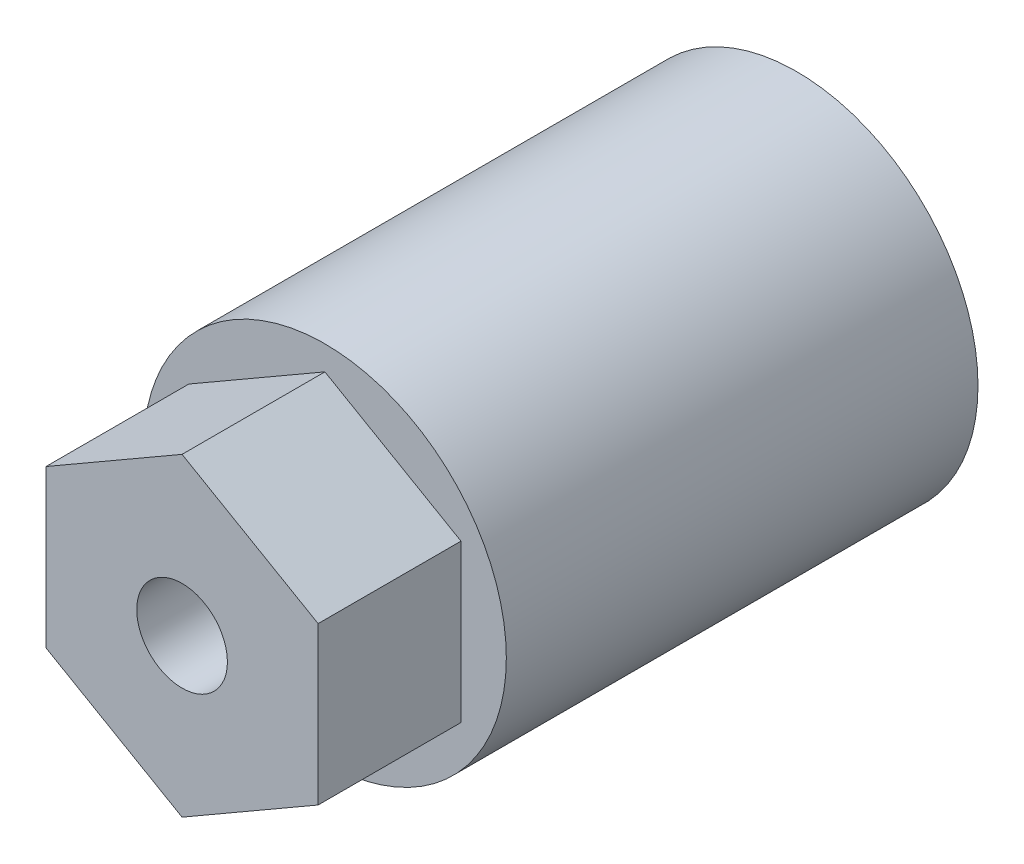
from build123d import *

# Parameters (mm, degrees)
CROQUIS1_R              = 8
CROQUIS1_R_2            = 3.1
SALIENTE_EXTRUIR1_DEPTH = 20.8
CROQUIS2_R              = 3.1
CROQUIS2_R_2            = 2
SALIENTE_EXTRUIR2_DEPTH = 2.2
CROQUIS3_R              = 2
SALIENTE_EXTRUIR3_DEPTH = 6.3
CORTAR_EXTRUIR1_REACH   = 10
CROQUIS4_R              = 2.5


with BuildPart() as part:
    # Croquis1 → Saliente-Extruir1 (new body)
    with BuildSketch(Plane.XY):
        Circle(CROQUIS1_R)
        Circle(CROQUIS1_R_2, mode=Mode.SUBTRACT)
    extrude(amount=SALIENTE_EXTRUIR1_DEPTH)

    # Croquis2 → Saliente-Extruir2 (add)
    with BuildSketch(Plane.XY.offset(20.8)):
        Circle(CROQUIS2_R)
        Circle(CROQUIS2_R_2, mode=Mode.SUBTRACT)
    extrude(amount=-SALIENTE_EXTRUIR2_DEPTH)

    # Croquis3 → Saliente-Extruir3 (add)
    with BuildSketch(Plane.XY.offset(20.8)):
        Polygon((0, 6.92820323), (-6, 3.464101615), (-6, -3.464101615), (0, -6.92820323), (6, -3.464101615), (6, 3.464101615), align=None)
        Circle(CROQUIS3_R, mode=Mode.SUBTRACT)
    extrude(amount=SALIENTE_EXTRUIR3_DEPTH)

    # Croquis4 → Cortar-Extruir1 (cut, up to next)
    with BuildSketch(Plane(origin=(0, 0, 0), x_dir=(0, 0, -1), z_dir=(1, 0, 0)), mode=Mode.PRIVATE) as cortar_extruir1_sk1:
        with Locations((-6, 0)):
            Circle(CROQUIS4_R)
    cortar_extruir1_tool1 = extrude(cortar_extruir1_sk1.sketch, amount=-CORTAR_EXTRUIR1_REACH, mode=Mode.PRIVATE) & part.part
    add(cortar_extruir1_tool1.solids().sort_by_distance((0, 0, 6))[0], mode=Mode.SUBTRACT)


solid = part.part
